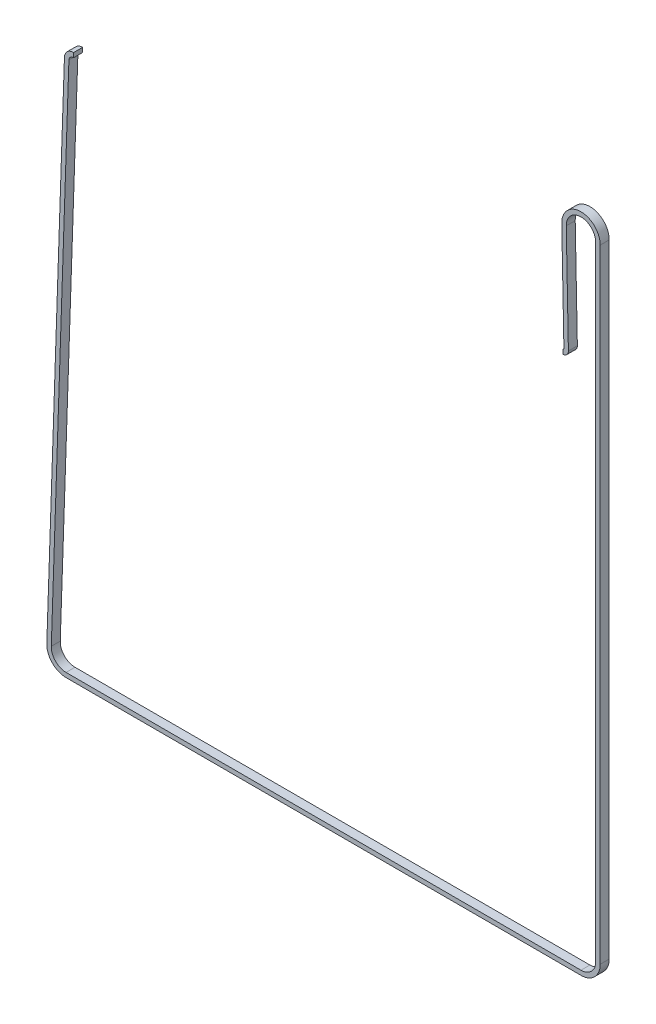
from build123d import *

# Parameters (mm, degrees)
EXTRUDE_THIN1_DEPTH = 6
SKETCH3_W           = 327.571594818
SKETCH3_H           = 11.174496413
CUT_EXTRUDE3_DEPTH  = 498.380052114


with BuildPart() as part:
    # Sketch2 → Extrude-Thin1 (new body)
    with BuildSketch(Plane.XY):
        with BuildLine():
            Line((-327.571523016, 7.498350769), (-0.016837352, -0.67478997))
            ThreePointArc((-0.016837352, -0.67478997), (0.476106699, -0.478484494), (0.674865476, 0.013475489))
            Line((0.674865476, 0.013475489), (-0.760216383, 71.883759331))
            ThreePointArc((-0.760216383, 71.883759331), (11.983695064, 85.015150307), (24.987217703, 72.140791802))
            Line((24.987217703, 72.140791802), (24.987217703, -344.844919852))
            ThreePointArc((24.987217703, -344.844919852), (21.212571133, -353.952564578), (12.101906255, -357.719915723))
            Line((12.101906255, -357.719915723), (-332.660093745, -357.443799484))
            ThreePointArc((-332.660093745, -357.443799484), (-341.911283403, -353.512528914), (-345.517294817, -344.129774518))
            Line((-345.517294817, -344.129774518), (-333.717699052, 1.704813786))
            ThreePointArc((-333.717699052, 1.704813786), (-331.836728158, 5.866260785), (-327.571523016, 7.498350769))
        make_face()
        with BuildLine():
            Line((-327.646355689, 4.499284236), (-0.091670025, -3.673856503))
            ThreePointArc((-0.091670025, -3.673856503), (2.592136472, -2.605082247), (3.674267594, 0.07336655))
            Line((3.674267594, 0.07336655), (2.239185734, 71.943650392))
            ThreePointArc((2.239185734, 71.943650392), (12.013642086, 82.015299782), (21.987217703, 72.140791802))
            Line((21.987217703, 72.140791802), (21.987217703, -344.844919852))
            ThreePointArc((21.987217703, -344.844919852), (19.092100431, -351.830394933), (12.104308922, -354.719916685))
            Line((12.104308922, -354.719916685), (-332.657691078, -354.443800446))
            ThreePointArc((-332.657691078, -354.443800446), (-339.753263728, -351.428554087), (-342.519039473, -344.23207256))
            Line((-342.519039473, -344.23207256), (-330.719443707, 1.602515744))
            ThreePointArc((-330.719443707, 1.602515744), (-329.778958261, 3.683239244), (-327.646355689, 4.499284236))
        make_face(mode=Mode.SUBTRACT)
    extrude(amount=EXTRUDE_THIN1_DEPTH)

    # Sketch3 → Cut-Extrude3 (cut, through all)
    with BuildSketch(Plane.XY):
        with Locations((-163.785725607, 1.911102563)):
            Rectangle(SKETCH3_W, SKETCH3_H)
    extrude(amount=CUT_EXTRUDE3_DEPTH, mode=Mode.SUBTRACT)


solid = part.part
